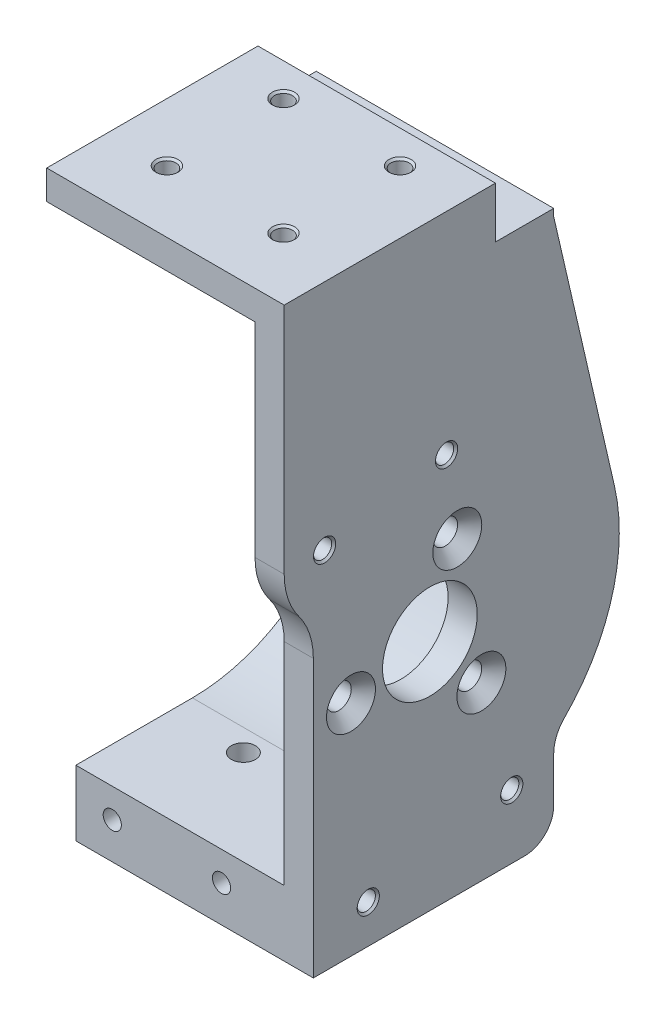
from build123d import *

# Parameters (mm, degrees)
MOTOR_SHELL_DEPTH                     = 32.6
MOTOR_MOUNT_DEPTH                     = 4
MOUNTING_HOLE_D                       = 3.4
MOUNTING_HOLE_CSINK_D                 = 6.72
MOUNTING_HOLE_CSINK_ANGLE             = 90
HOLE_DUPLICATION_COUNT                = 3
SKETCH11_R                            = 6.5
SHAFT_BASE_CUTOUT_DEPTH               = 33.6
M3X0_5_TAPPED_HOLE1_D                 = 2.5
M3X0_5_TAPPED_HOLE1_DEPTH             = 10
M3X0_5_TAPPED_HOLE1_CSINK_D           = 3.05
M3X0_5_TAPPED_HOLE1_CSINK_ANGLE       = 90
M3X0_5_TAPPED_HOLE1_TIP               = 0.751075774
M3X0_5_TAPPED_HOLE2_D                 = 2.5
M3X0_5_TAPPED_HOLE2_DEPTH             = 7.5
M3X0_5_TAPPED_HOLE2_CSINK_D           = 3.05
M3X0_5_TAPPED_HOLE2_CSINK_ANGLE       = 90
M3X0_5_TAPPED_HOLE2_TIP               = 0.751075774
M3X0_5_TAPPED_HOLE5_D                 = 2.5
M3X0_5_TAPPED_HOLE5_DEPTH             = 10
M3X0_5_TAPPED_HOLE5_TIP               = 0.751075774
M3X0_5_TAPPED_HOLE6_REACH             = 39
SKETCH26_R                            = 1.35
M3X0_5_TAPPED_HOLE6_DIRECTION_2_REACH = 11
M4X0_7_TAPPED_HOLE1_D                 = 3.3
M4X0_7_TAPPED_HOLE1_DEPTH             = 11.5
M4X0_7_TAPPED_HOLE1_TIP               = 0.991420021
ENLARGE_CAVITY_DEPTH                  = 28.6
MOD_1_DEPTH                           = 28.6
SKETCH31_W                            = 8
SKETCH31_H                            = 7
MOD_2_DEPTH                           = 32.6


with BuildPart() as part:
    # Motor Shell Profile → Motor Shell (new body)
    with BuildSketch(Plane(origin=(0, 0, 0), x_dir=(0, 0, -1), z_dir=(1, 0, 0))):
        with BuildLine():
            Line((25.335548996, 5.840373025), (17, 42))
            Line((17, 42), (17, 50))
            Line((17, 50), (-20, 50))
            Line((-20, 50), (-20, 46))
            Line((-20, 46), (10.895095859, 46))
            ThreePointArc((10.895095859, 46), (12.309309421, 45.414213562), (12.895095859, 44))
            Line((12.895095859, 44), (12.895095859, 42))
            Line((12.895095859, 42), (21.437772227, 4.941854098))
            ThreePointArc((21.437772227, 4.941854098), (17.215121117, -13.69816064), (0, -22))
            Line((0, -22), (-16, -22))
            Line((-16, -22), (-16, -32))
            Line((-16, -32), (13, -32))
            ThreePointArc((13, -32), (15.828427125, -30.828427125), (17, -28))
            Line((17, -28), (17, -21.840329668))
            ThreePointArc((17, -21.840329668), (17.377125597, -19.935327763), (18.451612903, -18.31769585))
            ThreePointArc((18.451612903, -18.31769585), (25.004638765, -7.125169489), (25.335548996, 5.840373025))
        make_face()
    extrude(amount=MOTOR_SHELL_DEPTH)

    # Sketch3 → Motor Mount (add)
    with BuildSketch(Plane(origin=(28.6, 0, 0), x_dir=(0, 0, -1), z_dir=(1, 0, 0))):
        with BuildLine():
            Line((-20, 46), (12.895095859, 46))
            Line((12.895095859, 46), (12.895095859, 42))
            Line((12.895095859, 42), (21.437772227, 4.941854098))
            ThreePointArc((21.437772227, 4.941854098), (17.215121117, -13.69816064), (0, -22))
            Line((0, -22), (-16, -22))
            Line((-16, -22), (-16, 6))
            ThreePointArc((-16, 6), (-16.513167019, 9.16227766), (-18, 12))
            ThreePointArc((-18, 12), (-19.486832981, 14.83772234), (-20, 18))
            Line((-20, 18), (-20, 46))
        make_face()
    extrude(amount=MOTOR_MOUNT_DEPTH)

    # Mounting Hole (through all)
    with Locations(Plane(origin=(32.6, 0, 0), x_dir=(0, 0, -1), z_dir=(1, 0, 0))):
        with Locations((7.070663707, -8.426488874)):
            mounting_hole = CounterSinkHole(MOUNTING_HOLE_D / 2, MOUNTING_HOLE_CSINK_D / 2, counter_sink_angle=MOUNTING_HOLE_CSINK_ANGLE)

    # Hole Duplication: Mounting Hole ×3 about axis
    hole_duplication_axis = Axis((0, 0, 0), (1, 0, 0))
    for i in range(1, HOLE_DUPLICATION_COUNT):
        add(mounting_hole.rotate(hole_duplication_axis, i * 360 / HOLE_DUPLICATION_COUNT), mode=Mode.SUBTRACT)

    # Sketch11 → Shaft Base Cutout (cut, through all)
    with BuildSketch(Plane(origin=(32.6, 0, 0), x_dir=(0, 0, -1), z_dir=(1, 0, 0))):
        Circle(SKETCH11_R)
    extrude(amount=-SHAFT_BASE_CUTOUT_DEPTH, mode=Mode.SUBTRACT)

    # M3x0.5 Tapped Hole1
    with Locations(Plane(origin=(32.6, 0, 0), x_dir=(0, 0, -1), z_dir=(1, 0, 0))):
        with Locations((-8.458892109, -26.736481777), (11.237262951, -23.263518223), (-14.452158477, 18.098247344), (2.289573324, 21.050266364)):
            CounterSinkHole(M3X0_5_TAPPED_HOLE1_D / 2, M3X0_5_TAPPED_HOLE1_CSINK_D / 2, depth=M3X0_5_TAPPED_HOLE1_DEPTH, counter_sink_angle=M3X0_5_TAPPED_HOLE1_CSINK_ANGLE)
            with Locations((0, 0, -(M3X0_5_TAPPED_HOLE1_DEPTH + M3X0_5_TAPPED_HOLE1_TIP / 2))):  # 118° drill point
                Cone(0, M3X0_5_TAPPED_HOLE1_D / 2, M3X0_5_TAPPED_HOLE1_TIP, mode=Mode.SUBTRACT)

    # M3x0.5 Tapped Hole2
    with Locations(Plane(origin=(0, 50, 0), x_dir=(1, 0, 0), z_dir=(0, 1, 0))):
        with Locations((8, 4.5), (8, -11.5), (24, -11.5), (24, 4.5)):
            CounterSinkHole(M3X0_5_TAPPED_HOLE2_D / 2, M3X0_5_TAPPED_HOLE2_CSINK_D / 2, depth=M3X0_5_TAPPED_HOLE2_DEPTH, counter_sink_angle=M3X0_5_TAPPED_HOLE2_CSINK_ANGLE)
            with Locations((0, 0, -(M3X0_5_TAPPED_HOLE2_DEPTH + M3X0_5_TAPPED_HOLE2_TIP / 2))):  # 118° drill point
                Cone(0, M3X0_5_TAPPED_HOLE2_D / 2, M3X0_5_TAPPED_HOLE2_TIP, mode=Mode.SUBTRACT)

    # M3x0.5 Tapped Hole5
    with Locations(Plane.XY.offset(16)):
        with Locations((5, -27), (20, -27)):
            Hole(M3X0_5_TAPPED_HOLE5_D / 2, depth=M3X0_5_TAPPED_HOLE5_DEPTH)
            with Locations((0, 0, -(M3X0_5_TAPPED_HOLE5_DEPTH + M3X0_5_TAPPED_HOLE5_TIP / 2))):  # 118° drill point
                Cone(0, M3X0_5_TAPPED_HOLE5_D / 2, M3X0_5_TAPPED_HOLE5_TIP, mode=Mode.SUBTRACT)

    # Sketch26 → M3x0.5 Tapped Hole6 (cut, up to next)
    with BuildSketch(Plane(origin=(0, 0, -17), x_dir=(-1, 0, 0), z_dir=(0, 0, -1)), mode=Mode.PRIVATE) as m3x0_5_tapped_hole6_sk1:
        with Locations((-10, 25.75)):
            Circle(SKETCH26_R)
    m3x0_5_tapped_hole6_tool1 = extrude(m3x0_5_tapped_hole6_sk1.sketch, amount=-M3X0_5_TAPPED_HOLE6_REACH, mode=Mode.PRIVATE) & part.part
    add(m3x0_5_tapped_hole6_tool1.solids().sort_by_distance((10, 25.75, -17))[0], mode=Mode.SUBTRACT)

    # Sketch26 → M3x0.5 Tapped Hole6 direction 2 (cut, up to next)
    with BuildSketch(Plane(origin=(0, 0, -17), x_dir=(-1, 0, 0), z_dir=(0, 0, -1)), mode=Mode.PRIVATE) as m3x0_5_tapped_hole6_direction_2_sk1:
        with Locations((-10, 25.75)):
            Circle(SKETCH26_R)
    m3x0_5_tapped_hole6_direction_2_tool1 = extrude(m3x0_5_tapped_hole6_direction_2_sk1.sketch, amount=M3X0_5_TAPPED_HOLE6_DIRECTION_2_REACH, mode=Mode.PRIVATE) & part.part
    add(m3x0_5_tapped_hole6_direction_2_tool1.solids().sort_by_distance((10, 25.75, -17))[0], mode=Mode.SUBTRACT)

    # M4x0.7 Tapped Hole1
    with Locations(Plane(origin=(0, -32, 0), x_dir=(-1, 0, 0), z_dir=(0, -1, 0))):
        with Locations((-10, -3)):
            Hole(M4X0_7_TAPPED_HOLE1_D / 2, depth=M4X0_7_TAPPED_HOLE1_DEPTH)
            with Locations((0, 0, -(M4X0_7_TAPPED_HOLE1_DEPTH + M4X0_7_TAPPED_HOLE1_TIP / 2))):  # 118° drill point
                Cone(0, M4X0_7_TAPPED_HOLE1_D / 2, M4X0_7_TAPPED_HOLE1_TIP, mode=Mode.SUBTRACT)

    # Sketch29 → Enlarge Cavity (cut)
    with BuildSketch(Plane.ZY):
        with BuildLine():
            Line((0, -23), (16, -23))
            Line((16, -23), (16, 6))
            ThreePointArc((16, 6), (16.513167019, 9.16227766), (18, 12))
            ThreePointArc((18, 12), (19.486832981, 14.83772234), (20, 18))
            Line((20, 18), (20, 46))
            Line((20, 46), (-11.921321894, 46))
            ThreePointArc((-11.921321894, 46), (-13.335535456, 45.414213562), (-13.921321894, 44))
            Line((-13.921321894, 44), (-13.921321894, 42))
            Line((-13.921321894, 42), (-22.412216419, 5.16648383))
            ThreePointArc((-22.412216419, 5.16648383), (-17.997626623, -14.320804305), (0, -23))
        make_face()
    extrude(amount=-ENLARGE_CAVITY_DEPTH, mode=Mode.SUBTRACT)

    # Sketch30 → Mod 1 (add)
    with BuildSketch(Plane.ZY):
        with BuildLine():
            Line((-16.457051563, 31), (3, 42))
            Line((3, 42), (3, 46))
            Line((3, 46), (-11.921321894, 46))
            ThreePointArc((-11.921321894, 46), (-13.335535456, 45.414213562), (-13.921321894, 44))
            Line((-13.921321894, 44), (-13.921321894, 42))
            Line((-13.921321894, 42), (-16.457051563, 31))
        make_face()
    extrude(amount=-MOD_1_DEPTH)

    # Sketch31 → Mod 2 (cut)
    with BuildSketch(Plane.ZY):
        with Locations((-13, 46.5)):
            Rectangle(SKETCH31_W, SKETCH31_H)
    extrude(amount=-MOD_2_DEPTH, mode=Mode.SUBTRACT)

    # Sketch33 → Hole1 (revolve, cut)
    with BuildSketch(Plane(origin=(17.5, 46.5, -9), x_dir=(0, 1, 0), z_dir=(1, 0, 0))):
        Polygon((0, 0), (0, 3.8), (2.55, 3.8), (2.55, 1.525705169), (2.65, 0), align=None)
    revolve(axis=Axis((17.5, 46.5, -15.445314094), (0, 0, 1)), mode=Mode.SUBTRACT)


solid = part.part
